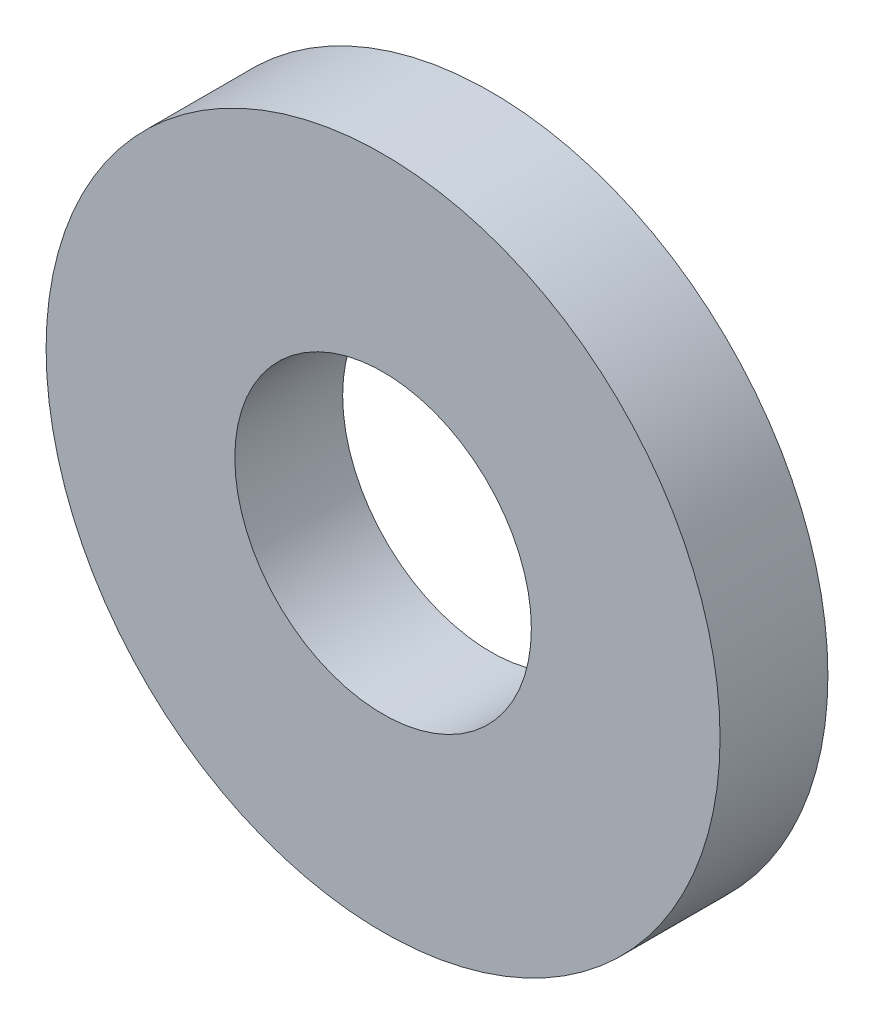
from build123d import *

# Parameters (mm, degrees)
SKETCH3_R           = 2.5
SKETCH3_R_2         = 1.1
BOSS_EXTRUDE1_DEPTH = 0.4


with BuildPart() as part:
    # Sketch3 → Boss-Extrude1 (new body, symmetric)
    with BuildSketch(Plane.XY):
        Circle(SKETCH3_R)
        Circle(SKETCH3_R_2, mode=Mode.SUBTRACT)
    extrude(amount=BOSS_EXTRUDE1_DEPTH, both=True)


solid = part.part
